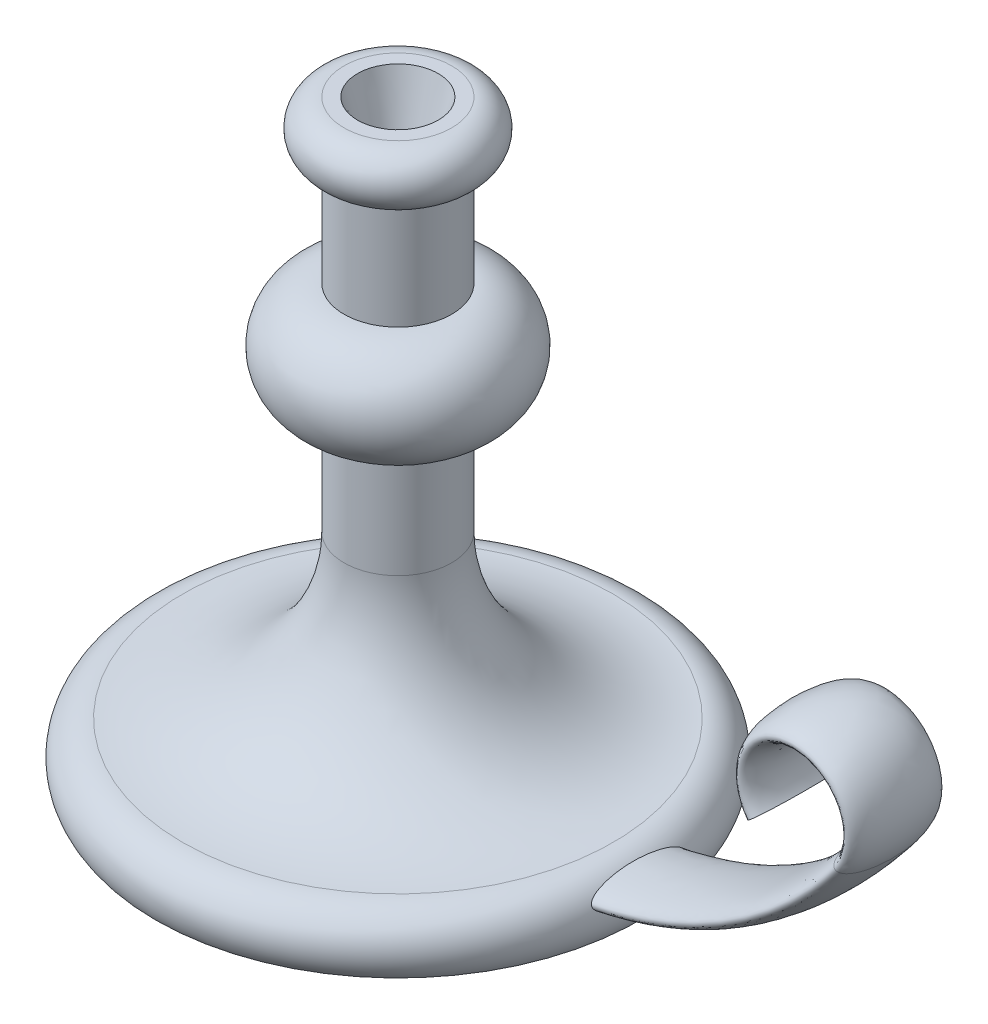
from build123d import *

# Parameters (mm, degrees)
SKETCH3_RX         = 17.5
SKETCH3_RY         = 5
SKETCH4_R          = 15
CUT_EXTRUDE1_DEPTH = 25
CUT_EXTRUDE1_TAPER = 15


with BuildPart() as part:
    # Sketch1 → Revolve1 (revolve)
    with BuildSketch(Plane.XY):
        with BuildLine():
            Line((0, 0), (0, 220))
            Line((0, 220), (20, 220))
            ThreePointArc((20, 220), (30, 210), (20, 200))
            Line((20, 200), (20, 160))
            ThreePointArc((20, 160), (40, 140), (20, 120))
            Line((20, 120), (20, 80))
            ThreePointArc((20, 80), (37.573593129, 37.573593129), (80, 20))
            ThreePointArc((80, 20), (91.180339887, 13.090169944), (90, 0))
            Line((90, 0), (0, 0))
        make_face()
    revolve(axis=Axis((0, 0, 0), (0, 1, 0)))

    # Sweep1: sweep along a path in Sketch2
    with BuildLine(Plane.XY) as sweep1_path:
        Line((0, 10), (60, 10))
        ThreePointArc((60, 10), (127.082039325, 25.83592135), (180, 70))
        ThreePointArc((180, 70), (164, 102), (148, 70))
    # Sketch3 → Sweep1 (sweep)
    with BuildSketch(Plane(origin=(0, 0, 0), x_dir=(0, 0, -1), z_dir=(1, 0, 0))):
        with Locations(Location((0, 10), (0, 0, 180))):
            Ellipse(SKETCH3_RX, SKETCH3_RY)
    sweep(path=sweep1_path.line)

    # Sketch4 → Cut-Extrude1 (cut)
    with BuildSketch(Plane(origin=(0, 220, 0), x_dir=(1, 0, 0), z_dir=(0, 1, 0))):
        Circle(SKETCH4_R)
    extrude(amount=-CUT_EXTRUDE1_DEPTH, taper=CUT_EXTRUDE1_TAPER, mode=Mode.SUBTRACT)


solid = part.part
